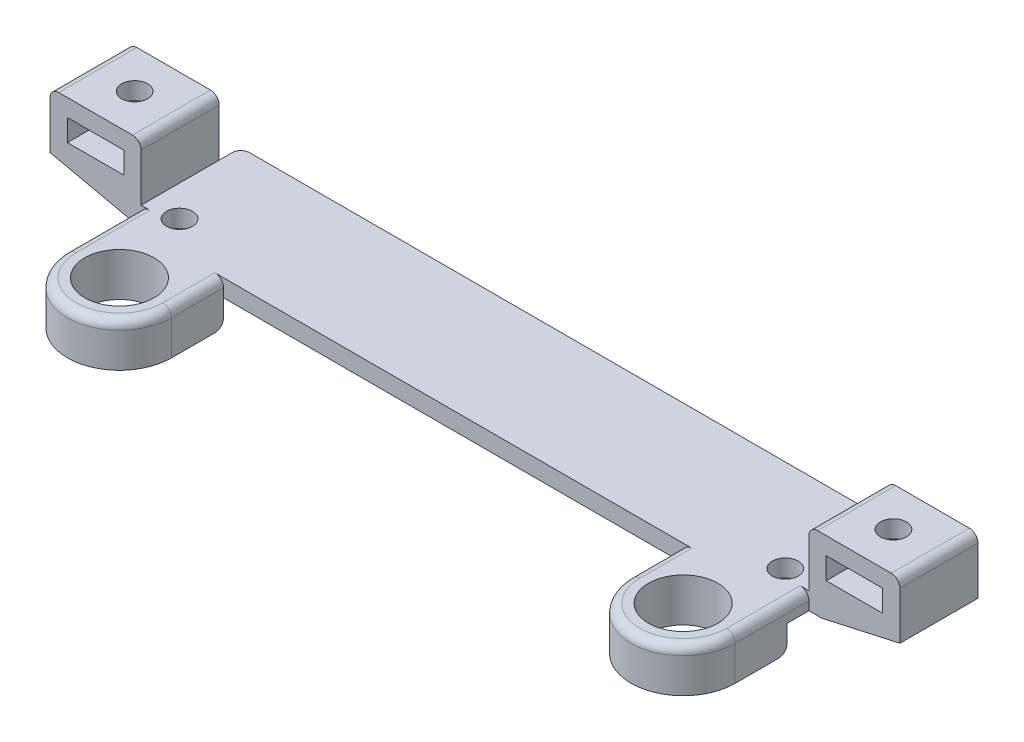
from build123d import *

# Parameters (mm, degrees)
SKETCH1_W           = 77
SKETCH1_H           = 14
BOSS_EXTRUDE1_DEPTH = 2
SKETCH3_W           = 9
SKETCH3_H           = 2
BOSS_EXTRUDE2_DEPTH = 10.5
SKETCH4_W           = 9
SKETCH4_H           = 2
BOSS_EXTRUDE3_DEPTH = 10.5
SKETCH5_W           = 10.5
SKETCH5_H           = 9
BOSS_EXTRUDE4_DEPTH = 6.5
SKETCH6_W           = 6.5
SKETCH6_H           = 2.5
CUT_EXTRUDE1_DEPTH  = 9
SKETCH8_R           = 1.5
CUT_EXTRUDE2_DEPTH  = 8.5
SKETCH10_W          = 9
SKETCH10_H          = 6
CUT_EXTRUDE4_DEPTH  = 2
CHAMFER1_SIZE       = 9
CHAMFER1_SIZE2      = 2
BOSS_EXTRUDE5_DEPTH = 5
SKETCH13_R          = 4
CUT_EXTRUDE5_DEPTH  = 5
FILLET3_R           = 1


with BuildPart() as part:
    # Sketch1 → Boss-Extrude1 (new body)
    with BuildSketch(Plane(origin=(0, 0, 0), x_dir=(1, 0, 0), z_dir=(0, 1, 0))):
        with Locations((-53.253755964, -5.729579977)):
            Rectangle(SKETCH1_W, SKETCH1_H)
    extrude(amount=BOSS_EXTRUDE1_DEPTH)

    # Sketch3 → Boss-Extrude2 (add)
    with BuildSketch(Plane.ZY.offset(91.753755964)):
        with Locations((5.729579977, 1)):
            Rectangle(SKETCH3_W, SKETCH3_H)
    extrude(amount=BOSS_EXTRUDE2_DEPTH)

    # Sketch4 → Boss-Extrude3 (add)
    with BuildSketch(Plane(origin=(-14.753755964, 0, 0), x_dir=(0, 0, -1), z_dir=(1, 0, 0))):
        with Locations((-5.729579977, 1)):
            Rectangle(SKETCH4_W, SKETCH4_H)
    extrude(amount=BOSS_EXTRUDE3_DEPTH)

    # Sketch5 → Boss-Extrude4 (add)
    with BuildSketch(Plane(origin=(0, 2, 0), x_dir=(1, 0, 0), z_dir=(0, 1, 0))):
        with Locations((-97.003755964, -5.729579977)):
            Rectangle(SKETCH5_W, SKETCH5_H)
        with Locations((-9.503755964, -5.729579977)):
            Rectangle(SKETCH5_W, SKETCH5_H)
    extrude(amount=BOSS_EXTRUDE4_DEPTH)

    # Sketch6 → Cut-Extrude1 (cut)
    with BuildSketch(Plane.XY.offset(10.229579977)):
        with Locations((-9.503755964, 5.25)):
            Rectangle(SKETCH6_W, SKETCH6_H)
        with Locations((-97.003755964, 5.25)):
            Rectangle(SKETCH6_W, SKETCH6_H)
    extrude(amount=-CUT_EXTRUDE1_DEPTH, mode=Mode.SUBTRACT)

    # Sketch8 → Cut-Extrude2 (cut)
    with BuildSketch(Plane(origin=(0, 8.5, 0), x_dir=(1, 0, 0), z_dir=(0, 1, 0))):
        with Locations((-88.178755964, -9.379579977)):
            Circle(SKETCH8_R)
        with Locations((-18.328755964, -9.379579977)):
            Circle(SKETCH8_R)
        with Locations((-97.003755964, -5.729579977)):
            Circle(SKETCH8_R)
        with Locations((-9.503755964, -5.729579977)):
            Circle(SKETCH8_R)
    extrude(amount=-CUT_EXTRUDE2_DEPTH, mode=Mode.SUBTRACT)

    # Sketch10 → Cut-Extrude4 (cut)
    with BuildSketch(Plane(origin=(0, 0, 0), x_dir=(-1, 0, 0), z_dir=(0, -1, 0))):
        with Locations((97.753755964, -5.729579977)):
            Rectangle(SKETCH10_W, SKETCH10_H)
        with Locations((8.753755964, -5.729579977)):
            Rectangle(SKETCH10_W, SKETCH10_H)
    extrude(amount=-CUT_EXTRUDE4_DEPTH, mode=Mode.SUBTRACT)

    # Chamfer1
    chamfer1_edges = [part.edges().sort_by_distance(p)[0] for p in [
        (-102.253755964, 0, 1.979579977),
        (-4.253755964, 0, 9.479579977),
        (-4.253755964, 0, 1.979579977),
        (-102.253755964, 0, 9.479579977),
    ]]
    chamfer1_side = [part.faces().sort_by_distance(p)[0] for p in [
        (-53.253755964, 0, 5.684508499),
    ]]
    chamfer(chamfer1_edges, length=CHAMFER1_SIZE, length2=CHAMFER1_SIZE2, reference=chamfer1_side[0])

    # Sketch12 → Boss-Extrude5 (add)
    with BuildSketch(Plane(origin=(0, 2, 0), x_dir=(1, 0, 0), z_dir=(0, 1, 0))):
        with BuildLine():
            Line((-26.753755964, -12.729579977), (-14.753755964, -12.729579977))
            Line((-14.753755964, -12.729579977), (-14.753755964, -18.729579977))
            ThreePointArc((-14.753755964, -18.729579977), (-20.753755964, -24.729579977), (-26.753755964, -18.729579977))
            Line((-26.753755964, -18.729579977), (-26.753755964, -12.729579977))
        make_face()
        with BuildLine():
            Line((-91.753755964, -12.729579977), (-91.753755964, -18.729579977))
            ThreePointArc((-91.753755964, -18.729579977), (-85.753755964, -24.729579977), (-79.753755964, -18.729579977))
            Line((-79.753755964, -18.729579977), (-79.753755964, -12.729579977))
            Line((-79.753755964, -12.729579977), (-91.753755964, -12.729579977))
        make_face()
    extrude(amount=-BOSS_EXTRUDE5_DEPTH)

    # Sketch13 → Cut-Extrude5 (cut)
    with BuildSketch(Plane(origin=(0, 2, 0), x_dir=(1, 0, 0), z_dir=(0, 1, 0))):
        with Locations((-85.753755964, -18.729579977)):
            Circle(SKETCH13_R)
        with Locations((-20.753755964, -18.729579977)):
            Circle(SKETCH13_R)
    extrude(amount=-CUT_EXTRUDE5_DEPTH, mode=Mode.SUBTRACT)

    # Fillet3
    fillet3_edges = [part.edges().sort_by_distance(p)[0] for p in [
        (-85.753755964, -3, 12.729579977),
        (-85.753755964, 2, 24.729579977),
        (-79.753755964, 2, 15.729579977),
        (-20.753755964, -3, 12.729579977),
        (-20.753755964, 2, 24.729579977),
        (-26.753755964, 2, 15.729579977),
        (-91.753755964, 8.5, 5.729579977),
        (-102.253755964, 8.5, 5.729579977),
        (-14.753755964, 8.5, 5.729579977),
        (-4.253755964, 8.5, 5.729579977),
        (-91.753755964, 1, -1.270420023),
        (-14.753755964, 1, -1.270420023),
    ]]
    fillet(fillet3_edges, radius=FILLET3_R)


solid = part.part
